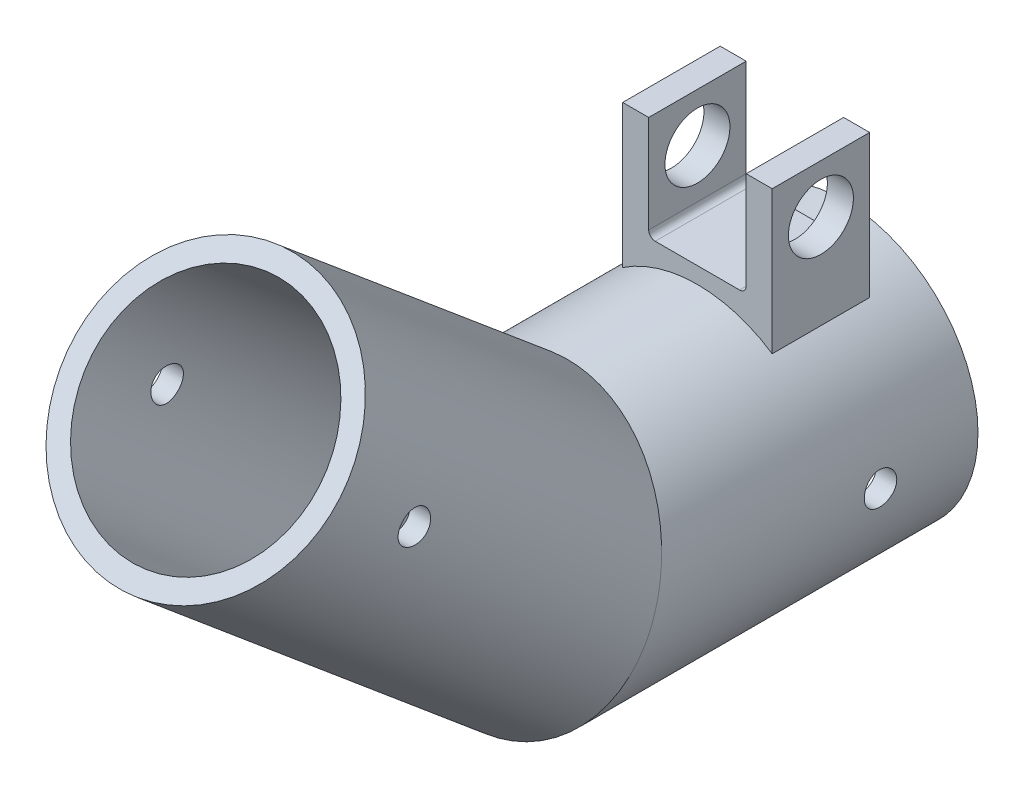
from build123d import *

# Parameters (mm, degrees)
SKETCH1_R                = 20.675
SKETCH1_R_2              = 17.5
CUT_EXTRUDE1_DEPTH       = 127.550540196
CUT_EXTRUDE1_DEPTH_BACK  = 127.550540196
SKETCH3_R                = 2.5
BOSS_EXTRUDE1_DEPTH      = 7.5
BOSS_EXTRUDE1_DEPTH_BACK = 7.5
CUT_EXTRUDE2_DEPTH       = 129.929493383
CUT_EXTRUDE2_DEPTH_BACK  = 129.929493383
SKETCH5_R                = 5


with BuildPart() as part:
    # Sweep1: sweep along a path in Sketch2
    with BuildLine(Plane(origin=(0, 0, 0), x_dir=(0, 0, -1), z_dir=(1, 0, 0))) as sweep1_path:
        Line((0, 0), (-50, 0))
        Line((-50, 0), (-98.168231432, 40.417945229))
    # Sketch1 → Sweep1 (sweep)
    with BuildSketch(Plane.XY):
        Circle(SKETCH1_R)
        Circle(SKETCH1_R_2, mode=Mode.SUBTRACT)
    sweep(path=sweep1_path.line, transition=Transition.RIGHT)

    # Sketch3 → Cut-Extrude1 (cut, two sides: drawn at the far end of the back side and taken through both)
    with BuildSketch(Plane(origin=(0, 0, 0), x_dir=(0, 0, -1), z_dir=(1, 0, 0)).offset(-CUT_EXTRUDE1_DEPTH_BACK)):
        with Locations((-86.677564785, 30.776131084)):
            Circle(SKETCH3_R)
        with Locations((-15, 0)):
            Circle(SKETCH3_R)
    extrude(amount=CUT_EXTRUDE1_DEPTH + CUT_EXTRUDE1_DEPTH_BACK, mode=Mode.SUBTRACT)

    # Sketch4 → Boss-Extrude1 (add, two sides: drawn at the far end of the back side and taken through both)
    with BuildSketch(Plane(origin=(0, 0, 15), x_dir=(-1, 0, 0), z_dir=(0, 0, -1)).offset(-BOSS_EXTRUDE1_DEPTH_BACK)):
        with BuildLine():
            Line((-11.5, 39.18154897), (-7.5, 39.18154897))
            Line((-7.5, 39.18154897), (-7.5, 24.18154897))
            ThreePointArc((-7.5, 24.18154897), (-7.207106781, 23.474442189), (-6.5, 23.18154897))
            Line((-6.5, 23.18154897), (6.5, 23.18154897))
            ThreePointArc((6.5, 23.18154897), (7.207106781, 23.474442189), (7.5, 24.18154897))
            Line((7.5, 24.18154897), (7.5, 39.18154897))
            Line((7.5, 39.18154897), (11.5, 39.18154897))
            Line((11.5, 39.18154897), (11.5, 17.18154897))
            Line((11.5, 17.18154897), (8.31426673, 17.18154897))
            ThreePointArc((8.31426673, 17.18154897), (0, 19.0875), (-8.31426673, 17.18154897))
            Line((-8.31426673, 17.18154897), (-11.5, 17.18154897))
            Line((-11.5, 17.18154897), (-11.5, 39.18154897))
        make_face()
    extrude(amount=BOSS_EXTRUDE1_DEPTH + BOSS_EXTRUDE1_DEPTH_BACK)

    # Sketch5 → Cut-Extrude2 (cut, two sides: drawn at the far end of the back side and taken through both)
    with BuildSketch(Plane(origin=(11.5, 0, 0), x_dir=(0, 0, -1), z_dir=(1, 0, 0)).offset(-CUT_EXTRUDE2_DEPTH_BACK)):
        with Locations((-15, 31.68154897)):
            Circle(SKETCH5_R)
    extrude(amount=CUT_EXTRUDE2_DEPTH + CUT_EXTRUDE2_DEPTH_BACK, mode=Mode.SUBTRACT)


solid = part.part
